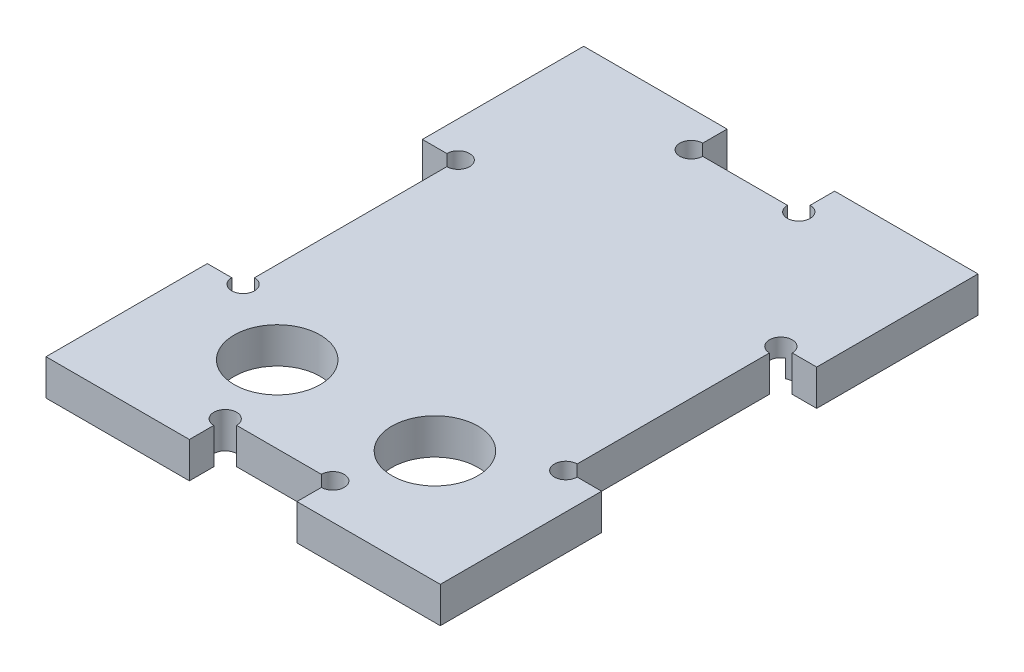
from build123d import *

# Parameters (mm, degrees)
SKETCH1_W               = 55
SKETCH1_H               = 75
BOSS_EXTRUDE1_DEPTH     = 5
SKETCH5_W               = 5
SKETCH5_H               = 30
SKETCH5_W_2             = 15
SKETCH5_H_2             = 5
CUT_EXTRUDE3_DEPTH      = 1
CUT_EXTRUDE3_DEPTH_BACK = 6
CUT_EXTRUDE4_DEPTH      = 2.5
SKETCH7_R               = 6
CUT_EXTRUDE5_DEPTH      = 6
SKETCH8_R               = 1.59
CUT_EXTRUDE6_DEPTH      = 6


with BuildPart() as part:
    # Sketch1 → Boss-Extrude1 (new body)
    with BuildSketch(Plane(origin=(0, 0, 0), x_dir=(1, 0, 0), z_dir=(0, 1, 0))):
        with Locations((27.5, 37.5)):
            Rectangle(SKETCH1_W, SKETCH1_H)
    extrude(amount=BOSS_EXTRUDE1_DEPTH)

    # Sketch5 → Cut-Extrude3 (cut, two sides)
    with BuildSketch(Plane(origin=(0, 5, 0), x_dir=(1, 0, 0), z_dir=(0, 1, 0))) as cut_extrude3_sk:
        with Locations((2.5, 37.5)):
            Rectangle(SKETCH5_W, SKETCH5_H)
        with Locations((27.5, 72.5)):
            Rectangle(SKETCH5_W_2, SKETCH5_H_2)
        with Locations((52.5, 37.5)):
            Rectangle(SKETCH5_W, SKETCH5_H)
        with Locations((27.5, 2.5)):
            Rectangle(SKETCH5_W_2, SKETCH5_H_2)
    extrude(amount=CUT_EXTRUDE3_DEPTH, mode=Mode.SUBTRACT)
    extrude(cut_extrude3_sk.sketch, amount=-CUT_EXTRUDE3_DEPTH_BACK, mode=Mode.SUBTRACT)

    # Sketch6 → Cut-Extrude4 (cut)
    with BuildSketch(Plane.XZ):
        with BuildLine():
            Line((7.3375, -70), (47.6625, -70))
            ThreePointArc((47.6625, -70), (48.785032015, -69.535032015), (49.25, -68.4125))
            Line((49.25, -68.4125), (49.25, -28.0875))
            ThreePointArc((49.25, -28.0875), (48.785032015, -26.964967985), (47.6625, -26.5))
            Line((47.6625, -26.5), (7.3375, -26.5))
            ThreePointArc((7.3375, -26.5), (6.214967985, -26.964967985), (5.75, -28.0875))
            Line((5.75, -28.0875), (5.75, -68.4125))
            ThreePointArc((5.75, -68.4125), (6.214967985, -69.535032015), (7.3375, -70))
        make_face()
    extrude(amount=-CUT_EXTRUDE4_DEPTH, mode=Mode.SUBTRACT)

    # Sketch7 → Cut-Extrude5 (cut, through all)
    with BuildSketch(Plane(origin=(0, 5, 0), x_dir=(1, 0, 0), z_dir=(0, 1, 0))):
        with Locations((16.5, 15.75)):
            Circle(SKETCH7_R)
        with Locations((38.5, 15.75)):
            Circle(SKETCH7_R)
    extrude(amount=-CUT_EXTRUDE5_DEPTH, mode=Mode.SUBTRACT)

    # Sketch8 → Cut-Extrude6 (cut, through all)
    with BuildSketch(Plane.XZ):
        with Locations((5, -22.5)):
            Circle(SKETCH8_R)
        with Locations((20, -5)):
            Circle(SKETCH8_R)
        with Locations((35, -5)):
            Circle(SKETCH8_R)
        with Locations((50, -22.5)):
            Circle(SKETCH8_R)
        with Locations((50, -52.5)):
            Circle(SKETCH8_R)
        with Locations((35, -70)):
            Circle(SKETCH8_R)
        with Locations((20, -70)):
            Circle(SKETCH8_R)
        with Locations((5, -52.5)):
            Circle(SKETCH8_R)
    extrude(amount=-CUT_EXTRUDE6_DEPTH, mode=Mode.SUBTRACT)


solid = part.part
